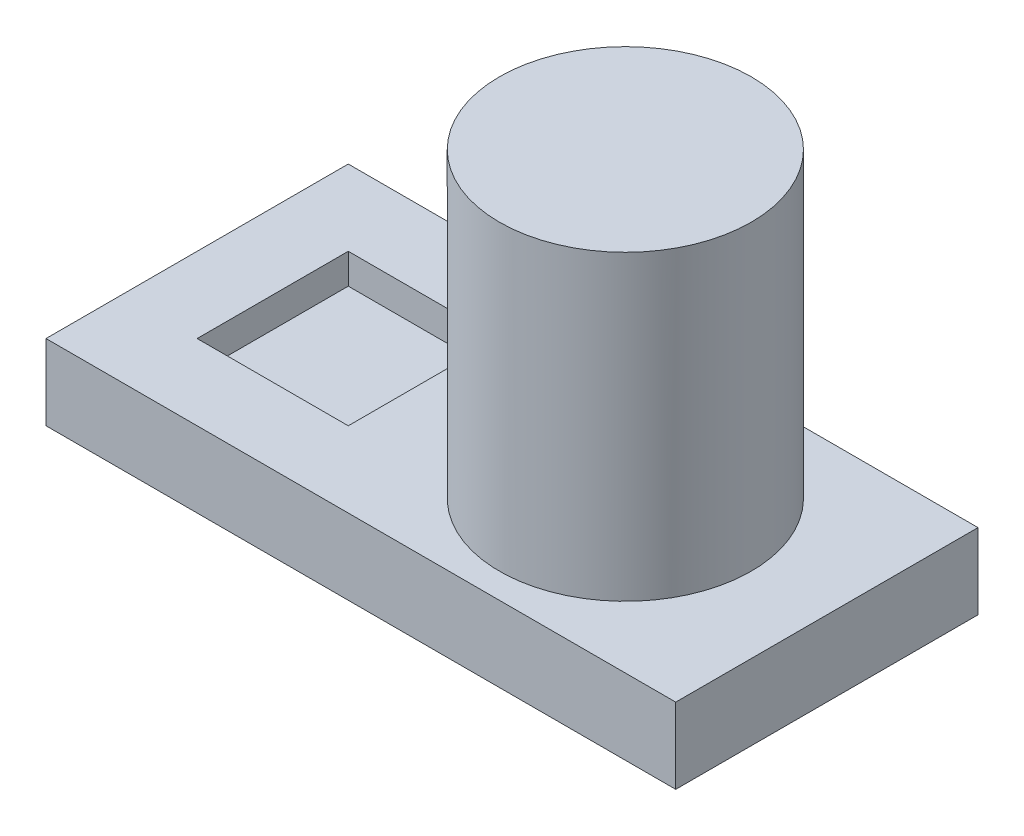
from build123d import *

# Parameters (mm, degrees)
SKETCH1_W          = 125
SKETCH1_H          = 60
EXTRUDE1_DEPTH     = 15
SKETCH2_R          = 25
EXTRUDE2_DEPTH     = 60
SKETCH3_W          = 30
SKETCH3_H          = 30
CUT_EXTRUDE1_DEPTH = 6


with BuildPart() as part:
    # Sketch1 → Extrude1 (new body)
    with BuildSketch(Plane(origin=(0, 0, 0), x_dir=(1, 0, 0), z_dir=(0, 1, 0))):
        with Locations((62.5, 30)):
            Rectangle(SKETCH1_W, SKETCH1_H)
    extrude(amount=EXTRUDE1_DEPTH)

    # Sketch2 → Extrude2 (add)
    with BuildSketch(Plane(origin=(0, 15, 0), x_dir=(-1, 0, 0), z_dir=(0, 1, 0))):
        with Locations(Location((-85, -30, 0), (0, 0, 270))):  # turned: the seam where the file's is
            Circle(SKETCH2_R)
    extrude(amount=EXTRUDE2_DEPTH)

    # Sketch3 → Cut-Extrude1 (cut)
    with BuildSketch(Plane(origin=(0, 15, 0), x_dir=(-1, 0, 0), z_dir=(0, 1, 0))):
        with Locations((-30, -30)):
            Rectangle(SKETCH3_W, SKETCH3_H)
    extrude(amount=-CUT_EXTRUDE1_DEPTH, mode=Mode.SUBTRACT)


solid = part.part
